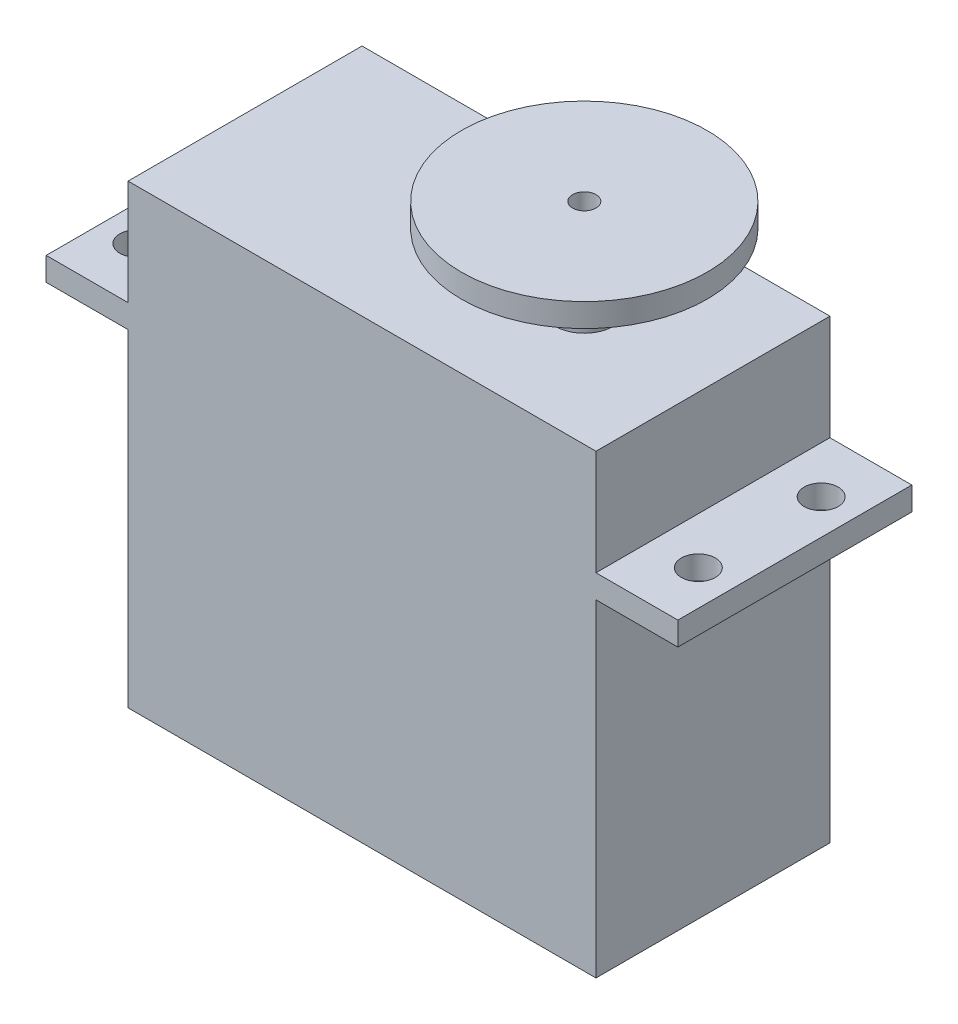
from build123d import *

# Parameters (mm, degrees)
SKETCH1_W           = 40
SKETCH1_H           = 20
BOSS_EXTRUDE1_DEPTH = 39
SKETCH2_W           = 20
SKETCH2_H           = 2
BOSS_EXTRUDE2_DEPTH = 7
SKETCH3_W           = 20
SKETCH3_H           = 2
BOSS_EXTRUDE3_DEPTH = 7
SKETCH4_R           = 1.45
CUT_EXTRUDE1_DEPTH  = 31
SKETCH5_R           = 2.5
BOSS_EXTRUDE4_DEPTH = 6
SKETCH6_R           = 10.5
BOSS_EXTRUDE5_DEPTH = 2
SKETCH7_R           = 1
CUT_EXTRUDE3_DEPTH  = 6


with BuildPart() as part:
    # Sketch1 → Boss-Extrude1 (new body)
    with BuildSketch(Plane(origin=(0, 0, 0), x_dir=(1, 0, 0), z_dir=(0, 1, 0))):
        Rectangle(SKETCH1_W, SKETCH1_H)
    extrude(amount=BOSS_EXTRUDE1_DEPTH)

    # Sketch2 → Boss-Extrude2 (add)
    with BuildSketch(Plane(origin=(20, 0, 0), x_dir=(0, 0, -1), z_dir=(1, 0, 0))):
        with Locations((0, 29)):
            Rectangle(SKETCH2_W, SKETCH2_H)
    extrude(amount=BOSS_EXTRUDE2_DEPTH)

    # Sketch3 → Boss-Extrude3 (add)
    with BuildSketch(Plane.ZY.offset(20)):
        with Locations((0, 29)):
            Rectangle(SKETCH3_W, SKETCH3_H)
    extrude(amount=BOSS_EXTRUDE3_DEPTH)

    # Sketch4 → Cut-Extrude1 (cut, through all)
    with BuildSketch(Plane(origin=(0, 30, 0), x_dir=(1, 0, 0), z_dir=(0, 1, 0))):
        with Locations((24, 5.25)):
            Circle(SKETCH4_R)
        with Locations((24, -5.25)):
            Circle(SKETCH4_R)
        with Locations((-24, 5.25)):
            Circle(SKETCH4_R)
        with Locations((-24, -5.25)):
            Circle(SKETCH4_R)
    extrude(amount=-CUT_EXTRUDE1_DEPTH, mode=Mode.SUBTRACT)

    # Sketch5 → Boss-Extrude4 (add)
    with BuildSketch(Plane(origin=(0, 39, 0), x_dir=(1, 0, 0), z_dir=(0, 1, 0))):
        with Locations((9, 0)):
            Circle(SKETCH5_R)
    extrude(amount=BOSS_EXTRUDE4_DEPTH)

    # Sketch6 → Boss-Extrude5 (add)
    with BuildSketch(Plane(origin=(0, 45, 0), x_dir=(1, 0, 0), z_dir=(0, 1, 0))):
        with Locations((9, 0)):
            Circle(SKETCH6_R)
    extrude(amount=BOSS_EXTRUDE5_DEPTH)

    # Sketch7 → Cut-Extrude3 (cut)
    with BuildSketch(Plane(origin=(0, 47, 0), x_dir=(1, 0, 0), z_dir=(0, 1, 0))):
        with Locations((9, 0)):
            Circle(SKETCH7_R)
    extrude(amount=-CUT_EXTRUDE3_DEPTH, mode=Mode.SUBTRACT)


solid = part.part
